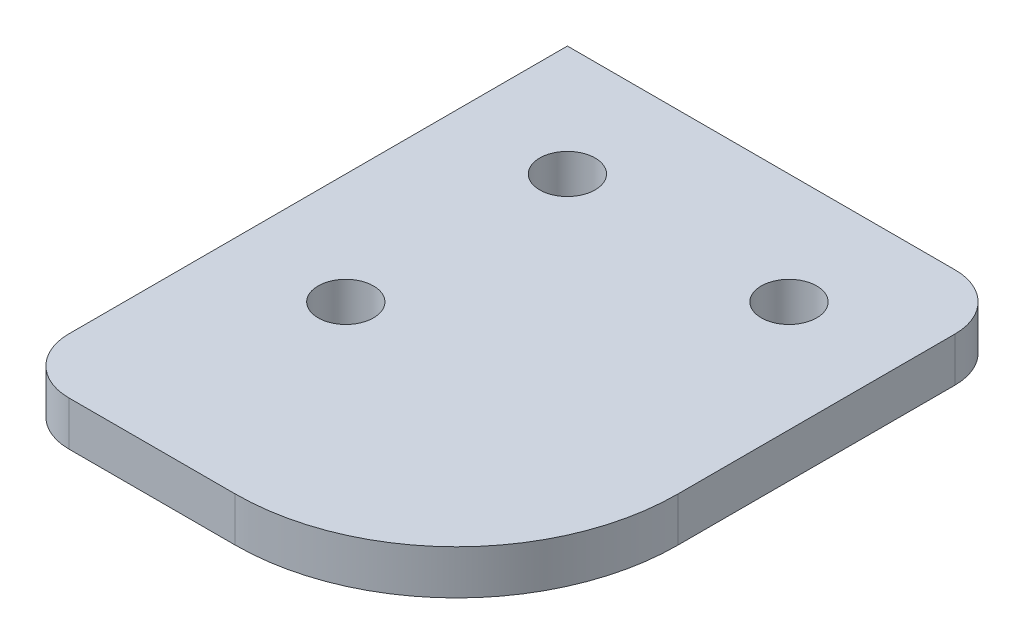
from build123d import *

# Parameters (mm, degrees)
SKETCH1_R           = 2.5
BOSS_EXTRUDE1_DEPTH = 4
FILLET1_R           = 5


with BuildPart() as part:
    # Sketch1 → Boss-Extrude1 (new body)
    with BuildSketch(Plane(origin=(0, 0, 0), x_dir=(1, 0, 0), z_dir=(0, 1, 0))):
        with BuildLine():
            Line((-20, 20), (20, 20))
            Line((20, 20), (20, -10))
            ThreePointArc((20, -10), (14.142135624, -24.142135624), (0, -30))
            Line((0, -30), (-20, -30))
            Line((-20, -30), (-20, 20))
        make_face()
        with Locations((-10, 10)):
            Circle(SKETCH1_R, mode=Mode.SUBTRACT)
        with Locations((10, 10)):
            Circle(SKETCH1_R, mode=Mode.SUBTRACT)
        with Locations((-10, -10)):
            Circle(SKETCH1_R, mode=Mode.SUBTRACT)
    extrude(amount=BOSS_EXTRUDE1_DEPTH)

    # Fillet1
    fillet1_edges = [part.edges().sort_by_distance(p)[0] for p in [
        (20, 2, -20),
        (-20, 2, 30),
    ]]
    fillet(fillet1_edges, radius=FILLET1_R)


solid = part.part
